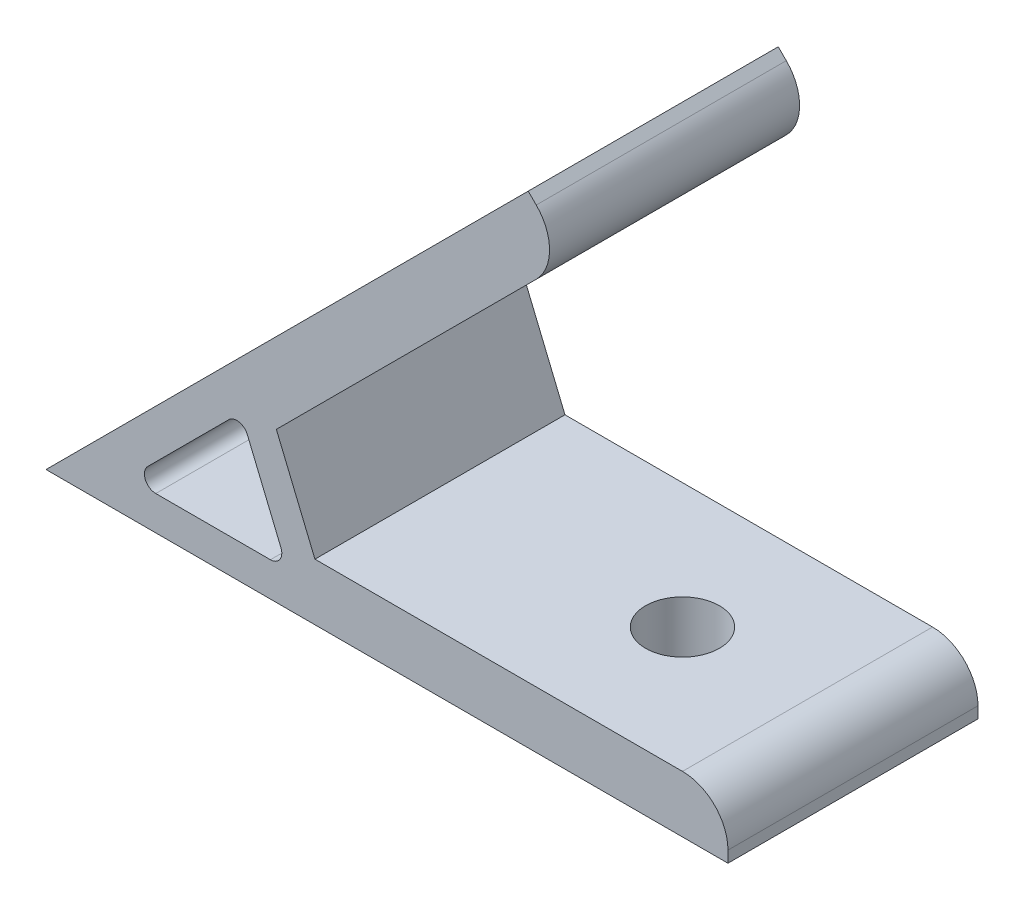
from build123d import *

# Parameters (mm, degrees)
EXTRUDE_1_DEPTH     = 11
SKETCH_2_R          = 3.25
CUT_EXTRUDE_1_DEPTH = 5
SKETCH_3_R          = 3.25
CUT_EXTRUDE_2_DEPTH = 5
FILLET_1_R          = 4
FILLET_2_R          = 1


with BuildPart() as part:
    # Эскиз1 → Бобышка-Вытянуть1 (new body, symmetric)
    with BuildSketch(Plane.XY):
        Polygon((0, 0), (42.426406871, 42.426406871), (45.961940777, 38.890872965), (20.266663343, 13.195595531), (23.661390163, 5), (60, 5), (60, 0), align=None)
        Polygon((17.142135624, 12.899494937), (21.242640687, 3), (7.242640687, 3), align=None, mode=Mode.SUBTRACT)
    extrude(amount=EXTRUDE_1_DEPTH, both=True)

    # Эскиз2 → Вырез-Вытянуть1 (cut)
    with BuildSketch(Plane(origin=(0, 0, 0), x_dir=(0, 0, 1), z_dir=(-0.707106781, 0.707106781, 0))):
        with Locations(Location((0, 45, 0), (0, 0, 270))):  # turned: the seam where the file's is
            Circle(SKETCH_2_R)
    extrude(amount=-CUT_EXTRUDE_1_DEPTH, mode=Mode.SUBTRACT)

    # Эскиз3 → Вырез-Вытянуть2 (cut)
    with BuildSketch(Plane.XZ):
        with Locations(Location((45, 0, 0), (0, 0, 270))):  # turned: the seam where the file's is
            Circle(SKETCH_3_R)
    extrude(amount=-CUT_EXTRUDE_2_DEPTH, mode=Mode.SUBTRACT)

    # Скругление1
    fillet_1_edges = [part.edges().sort_by_distance(p)[0] for p in [
        (45.961940777, 38.890872965, 0),
        (60, 5, 0),
    ]]
    fillet(fillet_1_edges, radius=FILLET_1_R)

    # Скругление2
    fillet_2_edges = [part.edges().sort_by_distance(p)[0] for p in [
        (17.142135624, 12.899494937, 0),
        (7.242640687, 3, 0),
        (21.242640687, 3, 0),
    ]]
    fillet(fillet_2_edges, radius=FILLET_2_R)


solid = part.part
